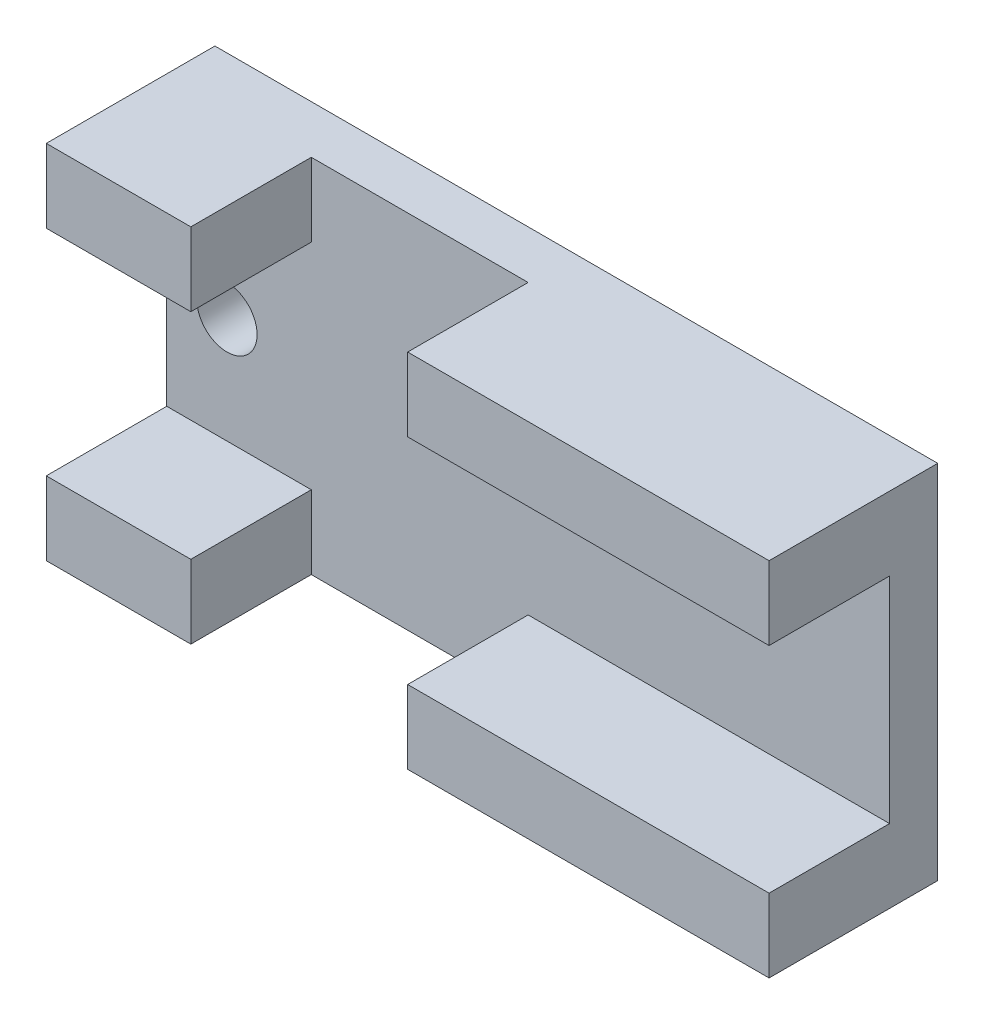
from build123d import *

# Parameters (mm, degrees)
SKETCH1_W           = 76.2
SKETCH1_H           = 38.1
BOSS_EXTRUDE1_DEPTH = 5.08
SKETCH2_W           = 38.1
SKETCH2_H           = 7.747
SKETCH2_W_2         = 15.24
BOSS_EXTRUDE2_DEPTH = 12.7
SKETCH3_R           = 3.175
CUT_EXTRUDE1_DEPTH  = 6.08
SKETCH4_R           = 3.175
CUT_EXTRUDE2_DEPTH  = 6.08


with BuildPart() as part:
    # Sketch1 → Boss-Extrude1 (new body)
    with BuildSketch(Plane.XY):
        Rectangle(SKETCH1_W, SKETCH1_H)
    extrude(amount=BOSS_EXTRUDE1_DEPTH)

    # Sketch2 → Boss-Extrude2 (add)
    with BuildSketch(Plane.XY.offset(5.08)):
        with Locations((19.05, 15.1765)):
            Rectangle(SKETCH2_W, SKETCH2_H)
        with Locations((19.05, -15.1765)):
            Rectangle(SKETCH2_W, SKETCH2_H)
        with Locations((-30.48, 15.1765)):
            Rectangle(SKETCH2_W_2, SKETCH2_H)
        with Locations((-30.48, -15.1765)):
            Rectangle(SKETCH2_W_2, SKETCH2_H)
    extrude(amount=BOSS_EXTRUDE2_DEPTH)

    # Sketch3 → Cut-Extrude1 (cut, through all)
    with BuildSketch(Plane.XY.offset(5.08)):
        with Locations((25.4, 6.35)):
            Circle(SKETCH3_R)
    extrude(amount=-CUT_EXTRUDE1_DEPTH, mode=Mode.SUBTRACT)

    # Sketch4 → Cut-Extrude2 (cut, through all)
    with BuildSketch(Plane.XY.offset(5.08)):
        with Locations((-31.75, 0)):
            Circle(SKETCH4_R)
    extrude(amount=-CUT_EXTRUDE2_DEPTH, mode=Mode.SUBTRACT)


solid = part.part
